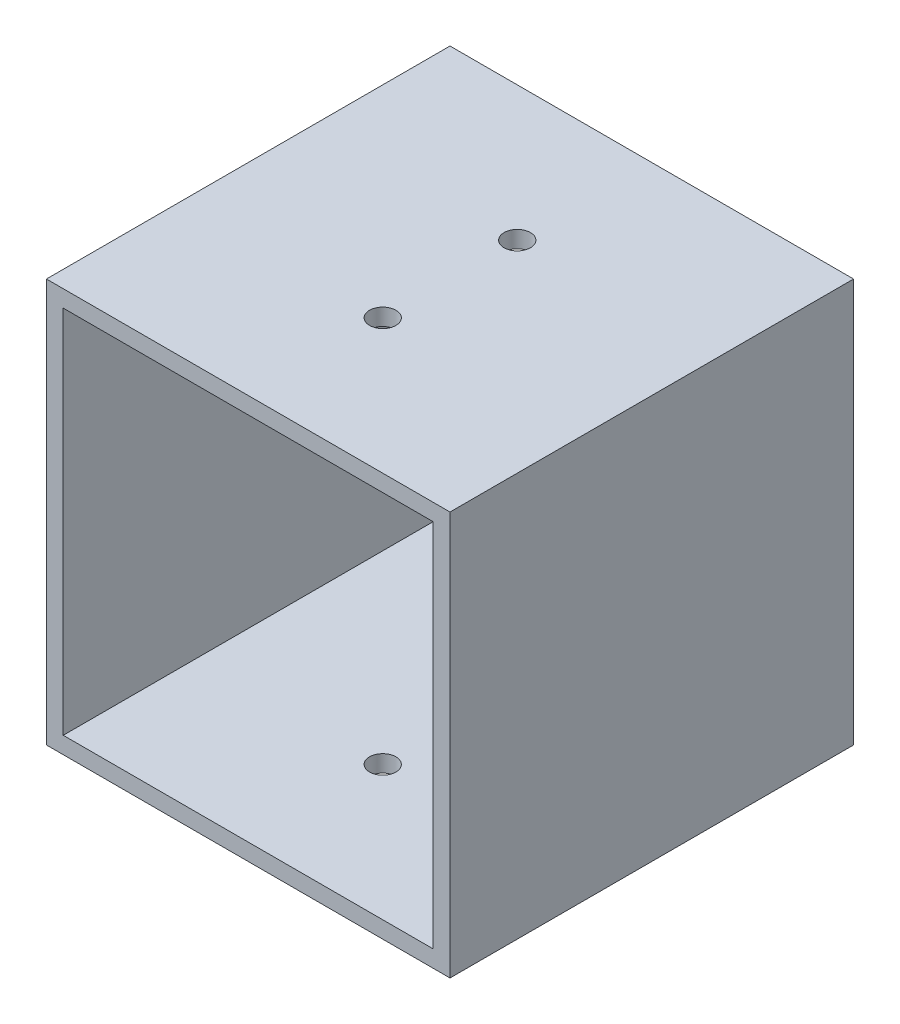
from build123d import *

# Parameters (mm, degrees)
SKETCH1_W           = 76.2
SKETCH1_H           = 76.2
SKETCH1_W_2         = 69.85
SKETCH1_H_2         = 69.85
EXTRUDE_THIN1_DEPTH = 38.1
SKETCH2_R           = 2.4892
CUT_EXTRUDE1_DEPTH  = 77.2


with BuildPart() as part:
    # Sketch1 → Extrude-Thin1 (new body, symmetric)
    with BuildSketch(Plane.XY):
        Rectangle(SKETCH1_W, SKETCH1_H)
        Rectangle(SKETCH1_W_2, SKETCH1_H_2, mode=Mode.SUBTRACT)
    extrude(amount=EXTRUDE_THIN1_DEPTH, both=True)

    # Sketch2 → Cut-Extrude1 (cut, through all)
    with BuildSketch(Plane.XZ.offset(38.1)):
        with Locations((0, 12.7)):
            Circle(SKETCH2_R)
        with Locations((0, -12.7)):
            Circle(SKETCH2_R)
    extrude(amount=-CUT_EXTRUDE1_DEPTH, mode=Mode.SUBTRACT)


solid = part.part
